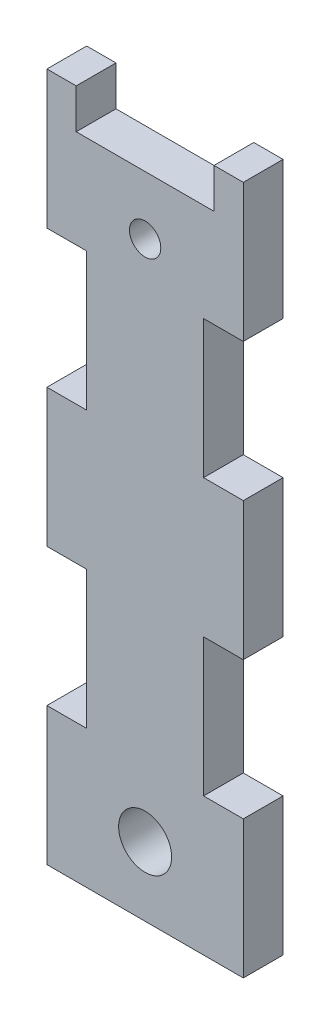
from build123d import *

# Parameters (mm, degrees)
SKETCH1_R           = 3.75
BOSS_EXTRUDE1_DEPTH = 9.525
SKETCH2_R           = 6.35
CUT_EXTRUDE1_DEPTH  = 10.525


with BuildPart() as part:
    # Sketch1 → Boss-Extrude1 (new body)
    with BuildSketch(Plane.XY):
        Polygon((40.03500006, -9.525), (7.01500006, -9.525), (7.01500006, 0), (0, 0), (0, -33.02), (9.525, -33.02), (9.525, -66.04), (0, -66.04), (0, -99.06), (9.525, -99.06), (9.525, -132.08), (0, -132.08), (0, -165.1), (47.05000012, -165.1), (47.05000012, -132.08), (37.52500012, -132.08), (37.52500012, -99.06), (47.05000012, -99.06), (47.05000012, -66.04), (37.52500012, -66.04), (37.52500012, -33.02), (47.05000012, -33.02), (47.05000012, 0), (40.03500006, 0), align=None)
        with Locations((23.52500006, -23.525)):
            Circle(SKETCH1_R, mode=Mode.SUBTRACT)
    extrude(amount=BOSS_EXTRUDE1_DEPTH)

    # Sketch2 → Cut-Extrude1 (cut, through all)
    with BuildSketch(Plane.XY.offset(9.525)):
        with Locations((23.52500006, -148.59)):
            Circle(SKETCH2_R)
    extrude(amount=-CUT_EXTRUDE1_DEPTH, mode=Mode.SUBTRACT)


solid = part.part
